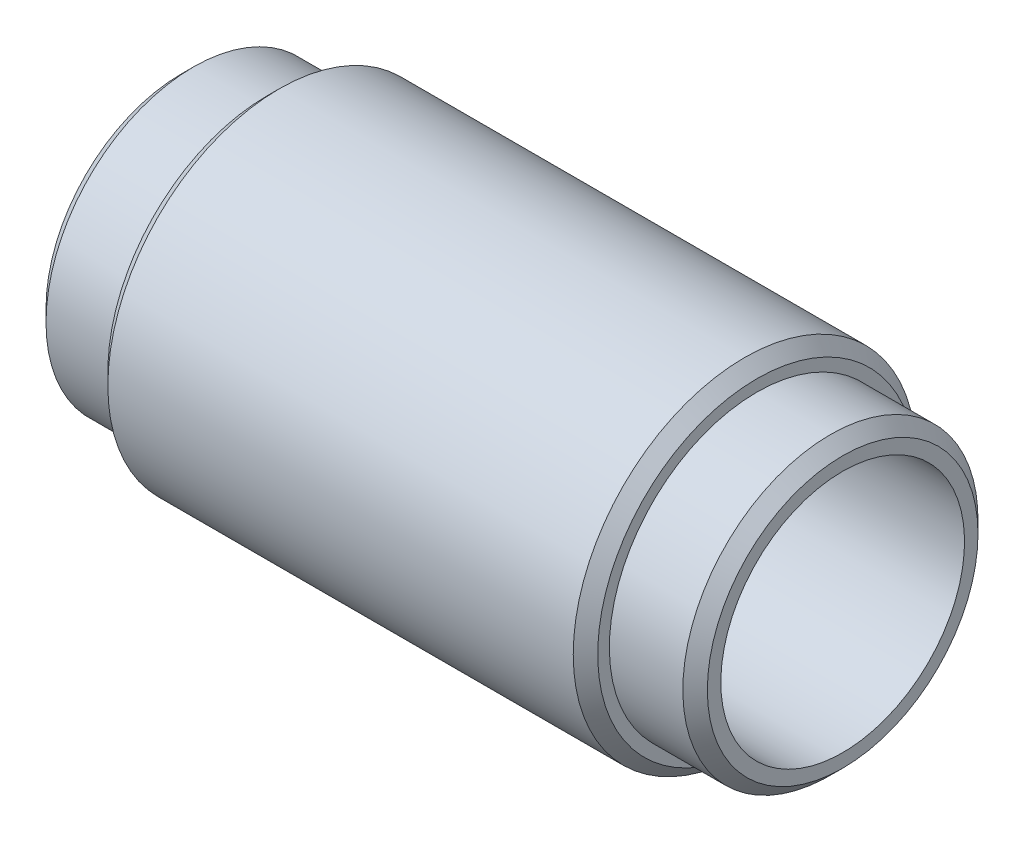
from build123d import *

# Parameters (mm, degrees)
CHAMFER_1_SIZE = 0.5


with BuildPart() as part:
    # 草图1 → 旋转1 (revolve)
    with BuildSketch(Plane.XY):
        Polygon((-13.5, 4.975), (13.5, 4.975), (13.5, 6.025), (10, 6.025), (10, 7), (-10, 7), (-10, 6.025), (-13.5, 6.025), align=None)
    revolve(axis=Axis((13.5, 0, 0), (-1, 0, 0)))

    # 倒角1
    chamfer_1_edges = [part.edges().sort_by_distance(p)[0] for p in [
        (-13.5, -6.025, 0),
        (13.5, -6.025, 0),
        (10, -7, 0),
        (-10, -7, 0),
    ]]
    chamfer(chamfer_1_edges, length=CHAMFER_1_SIZE)


solid = part.part
